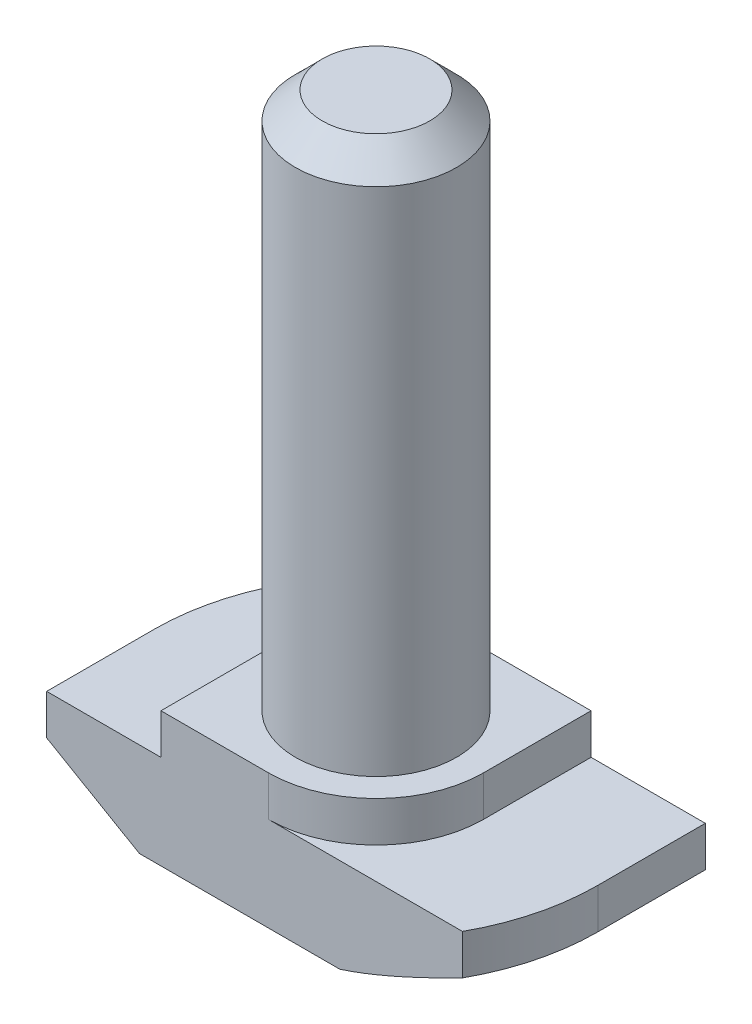
from build123d import *

# Parameters (mm, degrees)
EXTRUDE_1_DEPTH     = 4
SKETCH_2_R          = 3
EXTRUDE_2_DEPTH     = 20
CUT_EXTRUDE_1_DEPTH = 1.5
CUT_EXTRUDE_2_DEPTH = 4.5
CHAMFER_2_SIZE      = 1


with BuildPart() as part:
    # Эскиз1 → Бобышка-Вытянуть1 (new body, symmetric)
    with BuildSketch(Plane.XY):
        Polygon((8.25, 0), (-8.25, 0), (-8.25, 3.5), (-4, 3.5), (-4, 5), (4, 5), (4, 3.5), (8.25, 3.5), align=None)
    extrude(amount=EXTRUDE_1_DEPTH, both=True)

    # Эскиз2 → Бобышка-Вытянуть2 (add)
    with BuildSketch(Plane(origin=(0, 5, 0), x_dir=(1, 0, 0), z_dir=(0, 1, 0))):
        with Locations(Location((0, 0, 0), (0, 0, 270))):  # turned: the seam where the file's is
            Circle(SKETCH_2_R)
    extrude(amount=EXTRUDE_2_DEPTH)

    # Эскиз3 → Вырез-Вытянуть1 (cut)
    with BuildSketch(Plane(origin=(0, 5, 0), x_dir=(1, 0, 0), z_dir=(0, 1, 0))):
        with BuildLine():
            Line((-4, 0), (-4, 4))
            Line((-4, 4), (0, 4))
            ThreePointArc((0, 4), (-2.828427125, 2.828427125), (-4, 0))
        make_face()
        with BuildLine():
            Line((0, -4), (4, -4))
            Line((4, -4), (4, 0))
            ThreePointArc((4, 0), (2.828427125, -2.828427125), (0, -4))
        make_face()
    extrude(amount=-CUT_EXTRUDE_1_DEPTH, mode=Mode.SUBTRACT)

    # Эскиз4 → Вырез-Вытянуть2 (cut, through all)
    with BuildSketch(Plane(origin=(0, 3.5, 0), x_dir=(1, 0, 0), z_dir=(0, 1, 0))):
        with BuildLine():
            Line((-7.215434845, 4), (-8.25, 4))
            Line((-8.25, 4), (-8.25, 0))
            ThreePointArc((-8.25, 0), (-7.987172136, 2.065812495), (-7.215434845, 4))
        make_face()
        with BuildLine():
            Line((7.215434845, -4), (8.25, -4))
            Line((8.25, -4), (8.25, 0))
            ThreePointArc((8.25, 0), (7.987172136, -2.065812495), (7.215434845, -4))
        make_face()
    extrude(amount=-CUT_EXTRUDE_2_DEPTH, mode=Mode.SUBTRACT)

    # Вырез-По траектории1: sweep along a path in Эскиз6
    with BuildLine(Plane.XZ) as sweep_1_path:
        Line((0, -8.25), (8.25, -8.25))
        Line((8.25, -8.25), (8.25, 0))
        ThreePointArc((8.25, 0), (5.833630945, 5.833630945), (0, 8.25))
        Line((0, 8.25), (-8.25, 8.25))
        Line((-8.25, 8.25), (-8.25, 0))
        ThreePointArc((-8.25, 0), (-5.833630945, -5.833630945), (0, -8.25))
    # Эскиз5 → Вырез-По траектории1 (sweep, cut)
    with BuildSketch(Plane.XY.offset(4)):
        Polygon((-8.25, 2), (-4.8, 0), (-8.25, 0), align=None)
    sweep(path=sweep_1_path.line, transition=Transition.RIGHT, mode=Mode.SUBTRACT)

    # Фаска2
    chamfer_2_edges = [part.edges().sort_by_distance(p)[0] for p in [
        (0, 25, -3),
    ]]
    chamfer(chamfer_2_edges, length=CHAMFER_2_SIZE)


solid = part.part
